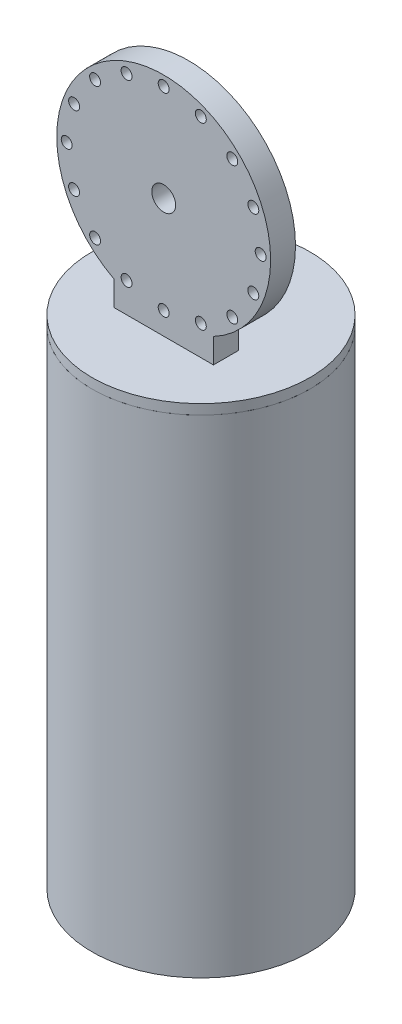
from build123d import *

# Parameters (mm, degrees)
ESBO_O1_W                = 3.76
ESBO_O1_H                = 490
ESBO_O3_R                = 109.54
RESSALTO_EXTRUS_O1_DEPTH = 10
RESSALTO_EXTRUS_O2_START = 12.5
ESBO_O4_R                = 12
ESBO_O4_R_2              = 5.5
RESSALTO_EXTRUS_O2_DEPTH = 25


with BuildPart() as part:
    # Esboço1 → Revolução1 (revolve)
    with BuildSketch(Plane.XY):
        with Locations((107.66, 245)):
            Rectangle(ESBO_O1_W, ESBO_O1_H)
    revolve(axis=Axis((0, 0, 0), (0, 1, 0)))


with BuildPart() as body_2:
    # Esboço3 → Ressalto-extrusão1 (new body)
    with BuildSketch(Plane(origin=(0, 490, 0), x_dir=(1, 0, 0), z_dir=(0, 1, 0))):
        Circle(ESBO_O3_R)
    extrude(amount=RESSALTO_EXTRUS_O1_DEPTH)

    # Esboço4 → Ressalto-extrusão2 (add)
    with BuildSketch(Plane.XY.offset(RESSALTO_EXTRUS_O2_START)):
        with BuildLine():
            Line((-50, 500), (-50, 524.835668447))
            ThreePointArc((-50, 524.835668447), (0, 727.5), (50, 524.835668447))
            Line((50, 524.835668447), (50, 500))
            Line((50, 500), (-50, 500))
        make_face()
        with Locations((0, 620)):
            Circle(ESBO_O4_R, mode=Mode.SUBTRACT)
        with Locations((0, 717.5)):
            Circle(ESBO_O4_R_2, mode=Mode.SUBTRACT)
        with Locations((37.311634656, 710.07825442)):
            Circle(ESBO_O4_R_2, mode=Mode.SUBTRACT)
        with Locations((68.942911166, 688.942911166)):
            Circle(ESBO_O4_R_2, mode=Mode.SUBTRACT)
        with Locations((90.07825442, 657.311634656)):
            Circle(ESBO_O4_R_2, mode=Mode.SUBTRACT)
        with Locations((97.5, 620)):
            Circle(ESBO_O4_R_2, mode=Mode.SUBTRACT)
        with Locations((90.07825442, 582.688365344)):
            Circle(ESBO_O4_R_2, mode=Mode.SUBTRACT)
        with Locations((68.942911166, 551.057088834)):
            Circle(ESBO_O4_R_2, mode=Mode.SUBTRACT)
        with Locations((37.311634656, 529.92174558)):
            Circle(ESBO_O4_R_2, mode=Mode.SUBTRACT)
        with Locations((0, 522.5)):
            Circle(ESBO_O4_R_2, mode=Mode.SUBTRACT)
        with Locations((-37.311634656, 529.92174558)):
            Circle(ESBO_O4_R_2, mode=Mode.SUBTRACT)
        with Locations((-68.942911166, 551.057088834)):
            Circle(ESBO_O4_R_2, mode=Mode.SUBTRACT)
        with Locations((-90.07825442, 582.688365344)):
            Circle(ESBO_O4_R_2, mode=Mode.SUBTRACT)
        with Locations((-97.5, 620)):
            Circle(ESBO_O4_R_2, mode=Mode.SUBTRACT)
        with Locations((-90.07825442, 657.311634656)):
            Circle(ESBO_O4_R_2, mode=Mode.SUBTRACT)
        with Locations((-68.942911166, 688.942911166)):
            Circle(ESBO_O4_R_2, mode=Mode.SUBTRACT)
        with Locations((-37.311634656, 710.07825442)):
            Circle(ESBO_O4_R_2, mode=Mode.SUBTRACT)
    extrude(amount=RESSALTO_EXTRUS_O2_DEPTH)


solid = Compound([part.part, body_2.part])
